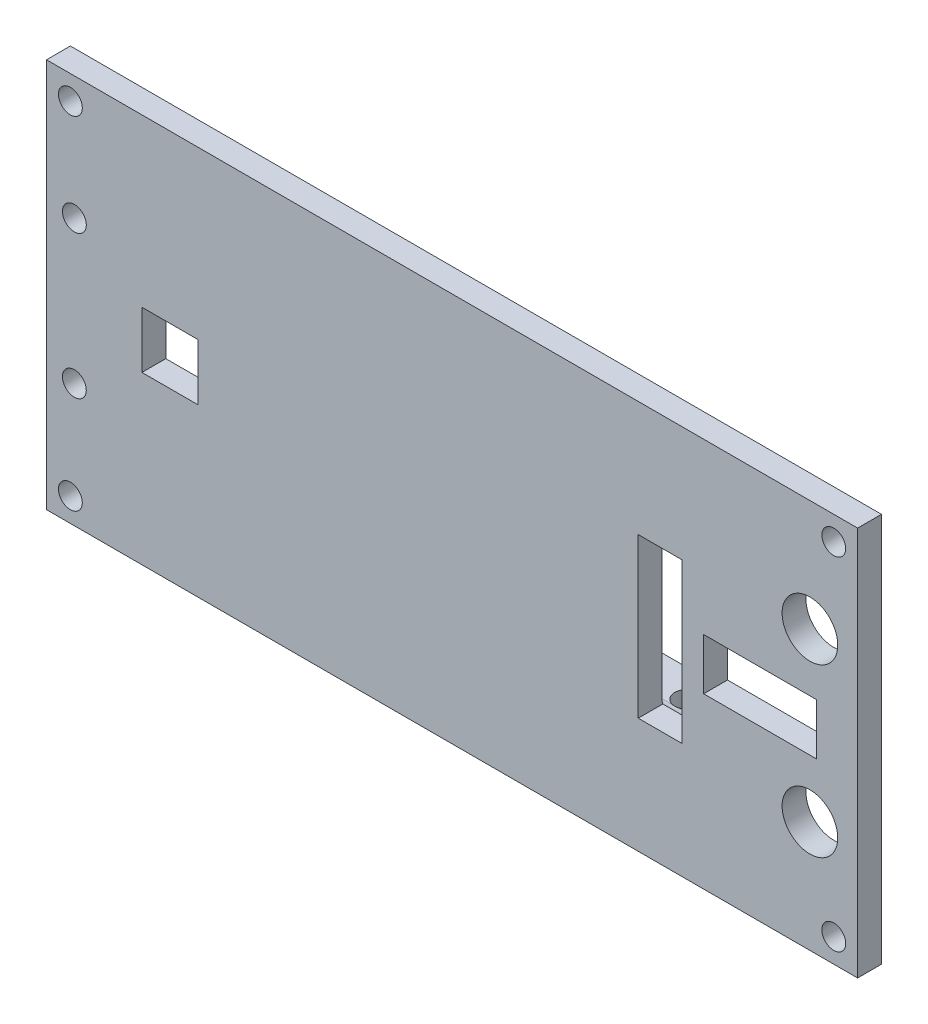
from build123d import *

# Parameters (mm, degrees)
SKETCH_1_W          = 102
SKETCH_1_H          = 49
EXTRUDE_1_DEPTH     = 3
SKETCH_2_R          = 1.5
CUT_EXTRUDE_1_DEPTH = 4
SKETCH_3_W          = 62
SKETCH_3_H          = 3
EXTRUDE_2_DEPTH     = 7
FILLET_1_R          = 2
FILLET_2_R          = 2
MM_PRESS_1_D        = 3
SKETCH_6_R          = 3.5
SKETCH_6_W          = 5.5
SKETCH_6_H          = 20
SKETCH_6_W_2        = 7.049620939
SKETCH_6_H_2        = 7.099016596
SKETCH_6_W_3        = 14.194500079
SKETCH_6_H_3        = 6.456669412
CUT_EXTRUDE_2_DEPTH = 7


with BuildPart() as part:
    # 草图1 → 凸台-拉伸1 (new body)
    with BuildSketch(Plane.XY):
        with Locations((82, -24.5)):
            Rectangle(SKETCH_1_W, SKETCH_1_H)
    extrude(amount=EXTRUDE_1_DEPTH)

    # 草图2 → 切除-拉伸1 (cut, through all)
    with BuildSketch(Plane(origin=(0, 0, 0), x_dir=(-1, 0, 0), z_dir=(0, 0, -1))):
        with Locations((-130, -46)):
            Circle(SKETCH_2_R)
        with Locations((-130, -3)):
            Circle(SKETCH_2_R)
        with Locations((-34, -3)):
            Circle(SKETCH_2_R)
        with Locations((-34.5, -15.5)):
            Circle(SKETCH_2_R)
        with Locations((-34, -46)):
            Circle(SKETCH_2_R)
        with Locations((-34.5, -33.5)):
            Circle(SKETCH_2_R)
    extrude(amount=-CUT_EXTRUDE_1_DEPTH, mode=Mode.SUBTRACT)

    # 草图3 → 凸台-拉伸2 (add)
    with BuildSketch(Plane(origin=(0, 0, 0), x_dir=(-1, 0, 0), z_dir=(0, 0, -1))):
        with Locations((-80, -11.6)):
            Rectangle(SKETCH_3_W, SKETCH_3_H)
        with Locations((-80, -37.4)):
            Rectangle(SKETCH_3_W, SKETCH_3_H)
    extrude(amount=EXTRUDE_2_DEPTH)

    # 圆角1
    fillet_1_edges = [part.edges().sort_by_distance(p)[0] for p in [
        (80, -13.1, 0),
    ]]
    fillet(fillet_1_edges, radius=FILLET_1_R)

    # 圆角2
    fillet_2_edges = [part.edges().sort_by_distance(p)[0] for p in [
        (80, -35.9, 0),
    ]]
    fillet(fillet_2_edges, radius=FILLET_2_R)

    # 大小mm Press 暗销孔1 (through all)
    with Locations(Plane(origin=(43.000752307, -10.1, 120.302802184), x_dir=(0.99978014, 0, -0.020968354), z_dir=(0, 1, 0))):
        with Locations((20.591231353, 123.39816829), (42.591231353, 122.936763059), (64.581557509, 122.475560716)):
            Hole(MM_PRESS_1_D / 2)

    # 草图6 → 切除-拉伸2 (cut)
    with BuildSketch(Plane.XY.offset(3)):
        with Locations((127, -14)):
            Circle(SKETCH_6_R)
        with Locations((127, -35)):
            Circle(SKETCH_6_R)
        with Locations((108.159552583, -24.5)):
            Rectangle(SKETCH_6_W, SKETCH_6_H)
        with Locations((46.525562777, -24.5)):
            Rectangle(SKETCH_6_W_2, SKETCH_6_H_2)
        with Locations((120.733739183, -24.5)):
            Rectangle(SKETCH_6_W_3, SKETCH_6_H_3)
    extrude(amount=-CUT_EXTRUDE_2_DEPTH, mode=Mode.SUBTRACT)


solid = part.part
